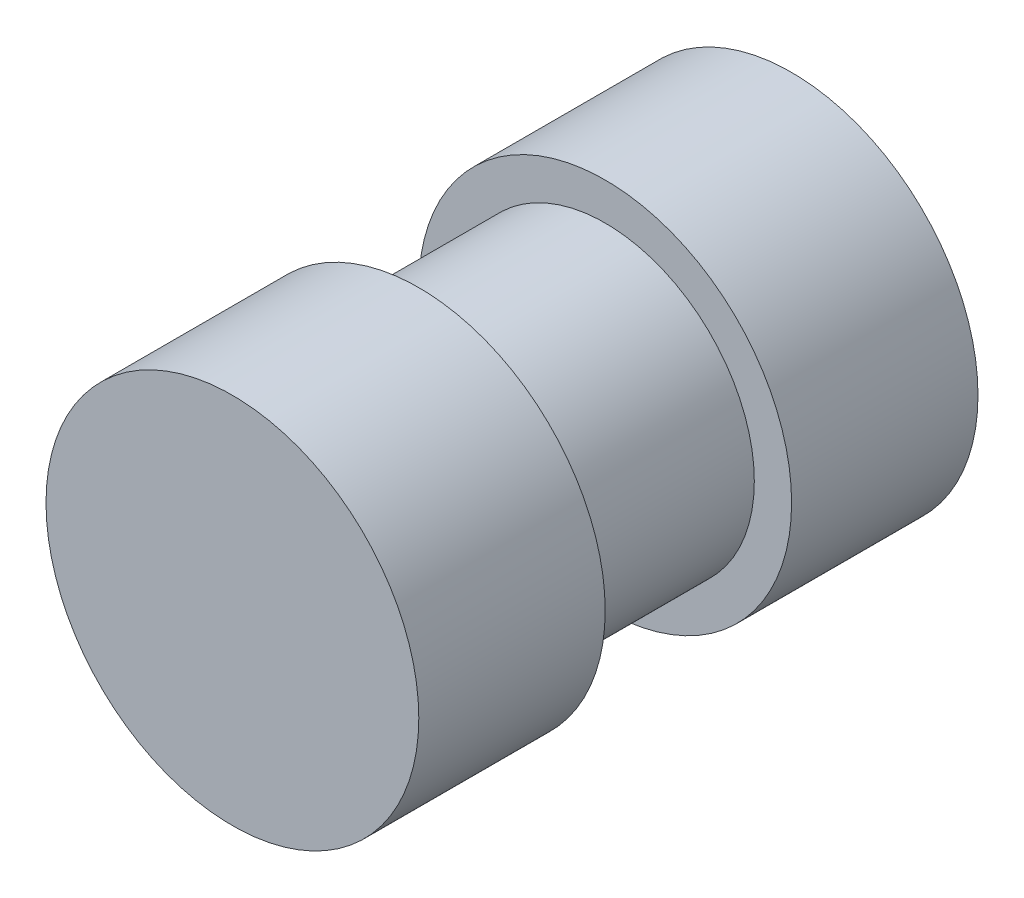
from build123d import *

# Parameters (mm, degrees)
SKETCH_1_R      = 4
EXTRUDE_1_DEPTH = 7.5
SKETCH_3_R      = 5
EXTRUDE_2_DEPTH = 5


with BuildPart() as part:
    # 草圖1 → 填料-伸長1 (new body, symmetric)
    with BuildSketch(Plane.XY):
        Circle(SKETCH_1_R)
    extrude(amount=EXTRUDE_1_DEPTH, both=True)

    # 草圖3 → 填料-伸長2 (add)
    with BuildSketch(Plane.XY.offset(7.5)):
        Circle(SKETCH_3_R)
    extrude_2 = extrude(amount=-EXTRUDE_2_DEPTH)

    # 鏡射1: 填料-伸長2 across plane
    add(extrude_2.mirror(Plane.XY))


solid = part.part
